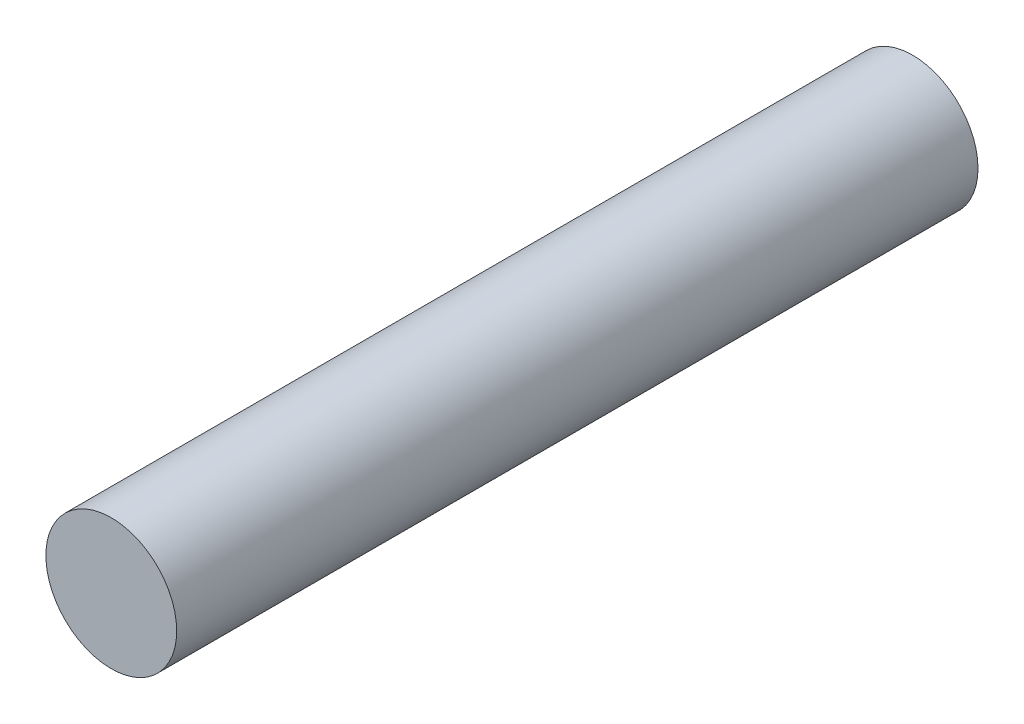
from build123d import *

# Parameters (mm, degrees)
SKETCH1_R           = 4
BOSS_EXTRUDE1_DEPTH = 49


with BuildPart() as part:
    # Sketch1 → Boss-Extrude1 (new body)
    with BuildSketch(Plane.XY):
        Circle(SKETCH1_R)
    extrude(amount=BOSS_EXTRUDE1_DEPTH)


solid = part.part
